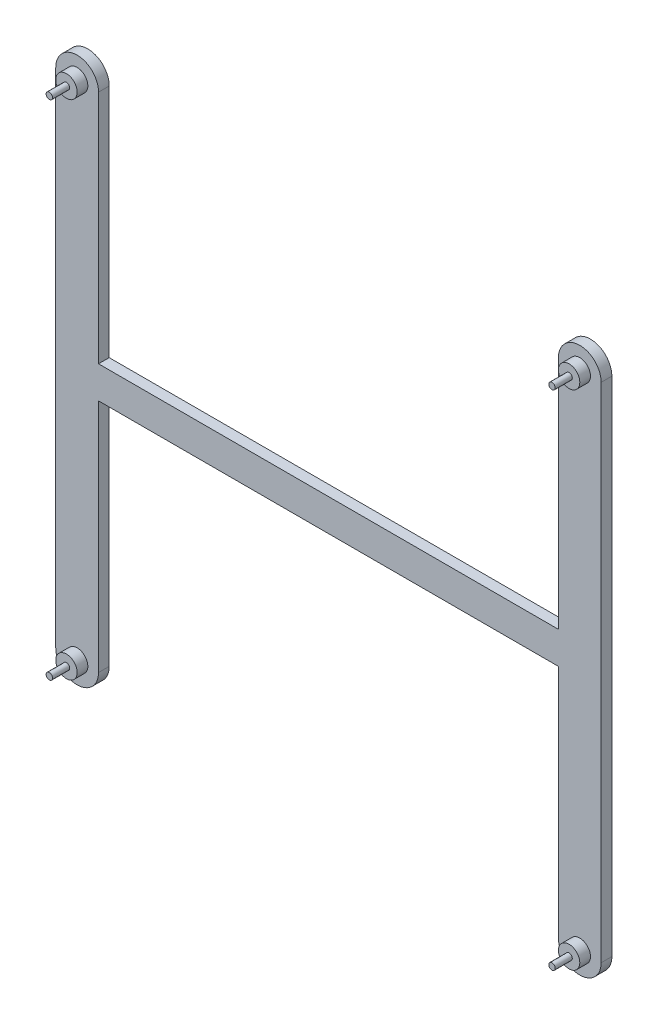
from build123d import *

# Parameters (mm, degrees)
BOSS_EXTRUDE1_DEPTH = 5
SKETCH3_R           = 5
BOSS_EXTRUDE2_DEPTH = 5
SKETCH4_R           = 1.5
BOSS_EXTRUDE3_DEPTH = 8


with BuildPart() as part:
    # Sketch1 → Boss-Extrude1 (new body)
    with BuildSketch(Plane.XY):
        with BuildLine():
            Line((-107.5, 7.5), (107.5, 7.5))
            Line((107.5, 7.5), (107.5, 117.5))
            ThreePointArc((107.5, 117.5), (117.5, 127.5), (127.5, 117.5))
            Line((127.5, 117.5), (127.5, -117.5))
            ThreePointArc((127.5, -117.5), (117.5, -127.5), (107.5, -117.5))
            Line((107.5, -117.5), (107.5, -7.5))
            Line((107.5, -7.5), (-107.5, -7.5))
            Line((-107.5, -7.5), (-107.5, -117.5))
            ThreePointArc((-107.5, -117.5), (-117.5, -127.5), (-127.5, -117.5))
            Line((-127.5, -117.5), (-127.5, 117.5))
            ThreePointArc((-127.5, 117.5), (-117.5, 127.5), (-107.5, 117.5))
            Line((-107.5, 117.5), (-107.5, 7.5))
        make_face()
    extrude(amount=BOSS_EXTRUDE1_DEPTH)

    # Sketch3 → Boss-Extrude2 (add)
    with BuildSketch(Plane.XY.offset(5)):
        with Locations((117.5, -117.5)):
            Circle(SKETCH3_R)
        with Locations((117.5, 117.5)):
            Circle(SKETCH3_R)
        with Locations((-117.5, 117.5)):
            Circle(SKETCH3_R)
        with Locations((-117.5, -117.5)):
            Circle(SKETCH3_R)
    extrude(amount=BOSS_EXTRUDE2_DEPTH)

    # Sketch4 → Boss-Extrude3 (add)
    with BuildSketch(Plane.XY.offset(10)):
        with Locations((-117.5, 117.5)):
            Circle(SKETCH4_R)
        with Locations((-117.5, -117.5)):
            Circle(SKETCH4_R)
        with Locations((117.5, -117.5)):
            Circle(SKETCH4_R)
        with Locations((117.5, 117.5)):
            Circle(SKETCH4_R)
    extrude(amount=BOSS_EXTRUDE3_DEPTH)


solid = part.part
